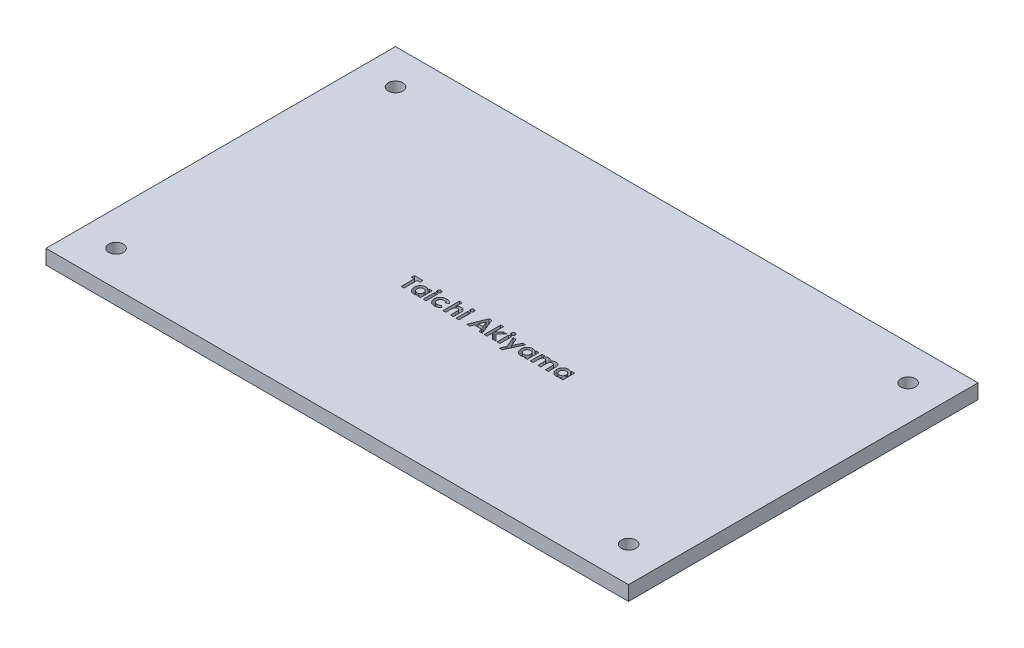
from build123d import *

# Parameters (mm, degrees)
SKETCH1_W           = 127
SKETCH1_H           = 76.2
BOSS_EXTRUDE1_DEPTH = 3.175
SKETCH2_R           = 1.5875
CUT_EXTRUDE1_DEPTH  = 3.175
SKETCH3_W           = 0.628205128
SKETCH3_H           = 2.557692308
CUT_EXTRUDE2_DEPTH  = 2.54


with BuildPart() as part:
    # Sketch1 → Boss-Extrude1 (new body)
    with BuildSketch(Plane(origin=(0, 0, 0), x_dir=(1, 0, 0), z_dir=(0, 1, 0))):
        with Locations((3.169007835, 6.5885369)):
            Rectangle(SKETCH1_W, SKETCH1_H)
    extrude(amount=BOSS_EXTRUDE1_DEPTH)

    # Sketch2 → Cut-Extrude1 (cut)
    with BuildSketch(Plane(origin=(0, 0, 0), x_dir=(1, 0, 0), z_dir=(0, 1, 0))):
        with Locations((-52.710992165, 37.0685369)):
            Circle(SKETCH2_R)
        with Locations((-52.710992165, -23.85921711)):
            Circle(SKETCH2_R)
        with Locations((59.049007835, 37.0685369)):
            Circle(SKETCH2_R)
        with Locations((59.049007835, -23.85921711)):
            Circle(SKETCH2_R)
    extrude(amount=CUT_EXTRUDE1_DEPTH, mode=Mode.SUBTRACT)

    # Sketch3 → Cut-Extrude2 (cut)
    with BuildSketch(Plane(origin=(0, 3.175, 0), x_dir=(1, 0, 0), z_dir=(0, 1, 0))):
        Polygon((-15.048272606, 3.5), (-13.163657221, 3.5), (-13.163657221, 2.871794872), (-13.79186235, 2.871794872), (-13.79186235, 0), (-14.420067478, 0), (-14.420067478, 2.871794872), (-15.048272606, 2.871794872), align=None)
        with BuildLine():
            Line((-10.830323888, 2.557692308), (-10.20211876, 2.557692308))
            Line((-10.20211876, 2.557692308), (-10.20211876, 0))
            Line((-10.20211876, 0), (-10.830323888, 0))
            Line((-10.830323888, 0), (-10.830323888, 0.279046474))
            add(Edge.make_bspline(
                [(-10.830323888, 0.279046474), (-10.861451221, 0.251884388), (-10.921863226, 0.199168144), (-11.017052999, 0.130767476), (-11.112520927, 0.074345765), (-11.208725737, 0.029408949), (-11.307146056, -0.003772264), (-11.40849047, -0.027796237), (-11.514218449, -0.041963762), (-11.586090872, -0.043892353), (-11.622591516, -0.044871795)],
                knots=[0, 0, 0, 0, 0.000123884, 0.000240435, 0.000351062, 0.000456148, 0.00055836, 0.000662098, 0.000768197, 0.000877682, 0.000877682, 0.000877682, 0.000877682], degree=3))
            add(Edge.make_bspline(
                [(-11.622591516, -0.044871795), (-11.663565112, -0.043950017), (-11.74453126, -0.042128532), (-11.863340094, -0.022954463), (-11.978061835, 0.006395724), (-12.08860336, 0.047929908), (-12.194763549, 0.101750066), (-12.297354851, 0.166451958), (-12.394618537, 0.244307005), (-12.487364294, 0.331946618), (-12.572281752, 0.428350817), (-12.646517396, 0.532181523), (-12.709092527, 0.641966128), (-12.760356984, 0.757340645), (-12.800683099, 0.878220396), (-12.829429848, 1.004988774), (-12.846390463, 1.137691055), (-12.84848971, 1.228082651), (-12.849554657, 1.273938301)],
                knots=[0, 0, 0, 0, 0.000122824, 0.000242708, 0.000360045, 0.000477637, 0.00059616, 0.000716559, 0.00084084, 0.00096929, 0.00109896, 0.001225617, 0.00135154, 0.001477401, 0.001603778, 0.001733212, 0.001866788, 0.002004323, 0.002004323, 0.002004323, 0.002004323], degree=3))
            add(Edge.make_bspline(
                [(-12.849554657, 1.273938301), (-12.848436991, 1.321421887), (-12.846244564, 1.414566232), (-12.830207091, 1.551251128), (-12.801990827, 1.681162718), (-12.763515923, 1.804480946), (-12.714024639, 1.921227119), (-12.653747563, 2.031592502), (-12.581864681, 2.13528862), (-12.499032402, 2.23055049), (-12.409593886, 2.317862595), (-12.313910485, 2.393874707), (-12.213478478, 2.458450533), (-12.108191138, 2.511169467), (-11.998063503, 2.551907991), (-11.883530352, 2.581691179), (-11.764083241, 2.599562137), (-11.6827149, 2.601555137), (-11.641521805, 2.602564103)],
                knots=[0, 0, 0, 0, 0.000142438, 0.000279408, 0.000412113, 0.000540727, 0.000666392, 0.0007919, 0.000917346, 0.001044118, 0.001170058, 0.00129182, 0.001410068, 0.00152765, 0.00164434, 0.001761677, 0.001882149, 0.002005674, 0.002005674, 0.002005674, 0.002005674], degree=3))
            add(Edge.make_bspline(
                [(-11.641521805, 2.602564103), (-11.603363651, 2.601771359), (-11.527862418, 2.600202805), (-11.416886484, 2.583171311), (-11.309255834, 2.557412387), (-11.205557598, 2.520710555), (-11.10494121, 2.474367027), (-11.009137335, 2.416295131), (-10.916050176, 2.348935605), (-10.859252373, 2.296326387), (-10.830323888, 2.26953125)],
                knots=[0, 0, 0, 0, 0.000114388, 0.000226333, 0.000336015, 0.000446, 0.000555788, 0.000667732, 0.000781602, 0.000899798, 0.000899798, 0.000899798, 0.000899798], degree=3))
            Line((-10.830323888, 2.26953125), (-10.830323888, 2.557692308))
        make_face()
        with BuildLine():
            add(Edge.make_bspline(
                [(-11.509710907, 2.019230769), (-11.53474303, 2.018462697), (-11.583804355, 2.016957326), (-11.655955749, 2.007902416), (-11.724910837, 1.99194726), (-11.790177836, 1.968376944), (-11.852729466, 1.939664864), (-11.911615869, 1.903703457), (-11.967323054, 1.861197838), (-12.019523399, 1.813177067), (-12.067111705, 1.76039346), (-12.108135602, 1.702795109), (-12.142999288, 1.641933961), (-12.172484904, 1.577627029), (-12.193589916, 1.509113362), (-12.210305076, 1.437284886), (-12.218979163, 1.3615548), (-12.220551501, 1.309947091), (-12.221349529, 1.283754006)],
                knots=[0, 0, 0, 0, 7.5102e-05, 0.000147195, 0.000217772, 0.000286959, 0.000355026, 0.000423925, 0.000493478, 0.00056493, 0.000636431, 0.00070628, 0.000776633, 0.000846612, 0.00091801, 0.00099132, 0.001067587, 0.001146191, 0.001146191, 0.001146191, 0.001146191], degree=3))
            add(Edge.make_bspline(
                [(-12.221349529, 1.283754006), (-12.220563691, 1.257323336), (-12.219015207, 1.205242005), (-12.210164825, 1.128873109), (-12.194051145, 1.055995388), (-12.170541893, 0.98719801), (-12.141831644, 0.92155267), (-12.106884814, 0.859362327), (-12.063958754, 0.801726584), (-12.016328731, 0.747281587), (-11.963057504, 0.698664318), (-11.907035106, 0.655496646), (-11.847496315, 0.619378283), (-11.785087086, 0.590187194), (-11.720017491, 0.566398909), (-11.651471754, 0.550644277), (-11.580121367, 0.540572639), (-11.531479924, 0.539170098), (-11.50690642, 0.538461538)],
                knots=[0, 0, 0, 0, 7.9304e-05, 0.000156268, 0.000230262, 0.000302763, 0.000374023, 0.000444985, 0.000516224, 0.000589238, 0.000661682, 0.000732217, 0.000801116, 0.000870115, 0.000938642, 0.001008537, 0.001080722, 0.001154423, 0.001154423, 0.001154423, 0.001154423], degree=3))
            add(Edge.make_bspline(
                [(-11.50690642, 0.538461538), (-11.481408045, 0.539233916), (-11.431417368, 0.540748197), (-11.358088861, 0.549720472), (-11.28820746, 0.565734128), (-11.222063907, 0.58943939), (-11.158647924, 0.617945374), (-11.098531783, 0.653204068), (-11.042367834, 0.695612148), (-10.989871633, 0.744067028), (-10.941768984, 0.797281645), (-10.900177759, 0.855635307), (-10.86395028, 0.917261705), (-10.835459035, 0.98361791), (-10.81283299, 1.053543), (-10.796599326, 1.127470944), (-10.787769153, 1.205481445), (-10.786234212, 1.258726651), (-10.785452093, 1.285857372)],
                knots=[0, 0, 0, 0, 7.6503e-05, 0.000149987, 0.000221246, 0.000291095, 0.000360435, 0.000429577, 0.000499689, 0.000571141, 0.000643632, 0.000714459, 0.000785771, 0.000857672, 0.000930619, 0.001005983, 0.001084339, 0.001165745, 0.001165745, 0.001165745, 0.001165745], degree=3))
            add(Edge.make_bspline(
                [(-10.785452093, 1.285857372), (-10.786224493, 1.312521457), (-10.787733215, 1.36460416), (-10.796637408, 1.440985838), (-10.812986322, 1.513462175), (-10.835146685, 1.58216639), (-10.864144799, 1.646941393), (-10.900399689, 1.707068983), (-10.941534682, 1.764632355), (-10.990169896, 1.81640935), (-11.042381713, 1.86451338), (-11.099371644, 1.905639009), (-11.159344196, 1.941082217), (-11.222667842, 1.970182458), (-11.28992893, 1.991514038), (-11.359929755, 2.0080303), (-11.433762474, 2.016951892), (-11.483981632, 2.018458747), (-11.509710907, 2.019230769)],
                knots=[0, 0, 0, 0, 8.0005e-05, 0.000156272, 0.000230267, 0.000302547, 0.000372526, 0.000442627, 0.000512887, 0.000584339, 0.000655319, 0.000725578, 0.000794719, 0.00086406, 0.000934123, 0.001006065, 0.00107955, 0.001156753, 0.001156753, 0.001156753, 0.001156753], degree=3))
        make_face(mode=Mode.SUBTRACT)
        with BuildLine():
            add(Edge.make_bspline(
                [(-9.306085106, 3.634615385), (-9.279009469, 3.633286951), (-9.225843848, 3.630678445), (-9.149676861, 3.605251308), (-9.079771004, 3.565344177), (-9.017972287, 3.510590642), (-8.966573893, 3.445204906), (-8.927303611, 3.372001228), (-8.905427773, 3.29089391), (-8.902389543, 3.234865823), (-8.900836708, 3.206229968)],
                knots=[0, 0, 0, 0, 8.0997e-05, 0.000159045, 0.000238182, 0.000321155, 0.000405032, 0.00048657, 0.000568724, 0.000654608, 0.000654608, 0.000654608, 0.000654608], degree=3))
            add(Edge.make_bspline(
                [(-8.900836708, 3.206229968), (-8.902333985, 3.177805144), (-8.905251499, 3.12241802), (-8.927807097, 3.042411771), (-8.965501206, 2.969243648), (-9.017315895, 2.904829012), (-9.078444633, 2.850957315), (-9.146822994, 2.810325694), (-9.22226008, 2.786313063), (-9.274600731, 2.7834865), (-9.301177253, 2.782051282)],
                knots=[0, 0, 0, 0, 8.5186e-05, 0.000165988, 0.000247203, 0.000330531, 0.000412514, 0.000490436, 0.000567604, 0.000647206, 0.000647206, 0.000647206, 0.000647206], degree=3))
            add(Edge.make_bspline(
                [(-9.301177253, 2.782051282), (-9.328489238, 2.783374966), (-9.382117398, 2.785974073), (-9.458909111, 2.811460703), (-9.529747334, 2.85105354), (-9.591277968, 2.906925775), (-9.643264989, 2.972776125), (-9.680819929, 3.047684049), (-9.704311473, 3.129345977), (-9.707099899, 3.186203877), (-9.708529016, 3.215344551)],
                knots=[0, 0, 0, 0, 8.1695e-05, 0.000160411, 0.000240158, 0.000323594, 0.000408023, 0.000490488, 0.000573505, 0.000660785, 0.000660785, 0.000660785, 0.000660785], degree=3))
            add(Edge.make_bspline(
                [(-9.708529016, 3.215344551), (-9.706973746, 3.243286705), (-9.703918642, 3.298175033), (-9.681911765, 3.377479097), (-9.64354195, 3.449452107), (-9.592513784, 3.513640896), (-9.531257867, 3.567373072), (-9.461393975, 3.606068197), (-9.385739595, 3.630445121), (-9.332910759, 3.633210943), (-9.306085106, 3.634615385)],
                knots=[0, 0, 0, 0, 8.3789e-05, 0.000164592, 0.000244563, 0.000326905, 0.000409417, 0.000487254, 0.000565091, 0.000645391, 0.000645391, 0.000645391, 0.000645391], degree=3))
        make_face()
        with Locations((-9.304682862, 1.278846154)):
            Rectangle(SKETCH3_W, SKETCH3_H)
        with BuildLine():
            Line((-5.939298247, 2.036057692), (-6.459530619, 1.75))
            add(Edge.make_bspline(
                [(-6.459530619, 1.75), (-6.483376175, 1.773879223), (-6.529213328, 1.819781094), (-6.602716887, 1.87788558), (-6.674907034, 1.925994478), (-6.74875987, 1.961496373), (-6.824935552, 1.988232703), (-6.906181644, 2.005940762), (-6.99344643, 2.017600889), (-7.053807582, 2.018676275), (-7.08493126, 2.019230769)],
                knots=[0, 0, 0, 0, 0.000101156, 0.000194447, 0.000280597, 0.000360872, 0.000439588, 0.000522252, 0.000609912, 0.000703227, 0.000703227, 0.000703227, 0.000703227], degree=3))
            add(Edge.make_bspline(
                [(-7.08493126, 2.019230769), (-7.11347382, 2.018541361), (-7.169329217, 2.017192247), (-7.250942815, 2.007115291), (-7.328508177, 1.991288235), (-7.401886069, 1.968133197), (-7.470945797, 1.937544132), (-7.536258455, 1.901346575), (-7.597189377, 1.858126697), (-7.652877287, 1.808498859), (-7.703145413, 1.75385971), (-7.747987147, 1.695584708), (-7.784723116, 1.63280936), (-7.81648364, 1.567009112), (-7.839834365, 1.496948089), (-7.856918323, 1.423262022), (-7.86665602, 1.345947647), (-7.86806684, 1.29312872), (-7.868785426, 1.266225962)],
                knots=[0, 0, 0, 0, 8.5609e-05, 0.000167529, 0.00024632, 0.00032282, 0.000397853, 0.000472558, 0.000546482, 0.000621476, 0.0006959, 0.000768959, 0.000841585, 0.000913719, 0.000987772, 0.001062605, 0.001140351, 0.001221056, 0.001221056, 0.001221056, 0.001221056], degree=3))
            add(Edge.make_bspline(
                [(-7.868785426, 1.266225962), (-7.868026178, 1.240025277), (-7.866543692, 1.188866583), (-7.857435797, 1.113702271), (-7.841624147, 1.042149054), (-7.817916649, 0.974585212), (-7.789500562, 0.910387902), (-7.753815158, 0.850067699), (-7.711851089, 0.793361199), (-7.663387432, 0.740761265), (-7.609701998, 0.693454078), (-7.55182489, 0.651676934), (-7.489928791, 0.616257645), (-7.423292672, 0.588461464), (-7.353002968, 0.56581339), (-7.278590283, 0.549687076), (-7.200133802, 0.540735856), (-7.146652006, 0.539231363), (-7.119286228, 0.538461538)],
                knots=[0, 0, 0, 0, 7.8604e-05, 0.00015348, 0.00022679, 0.000297963, 0.000367942, 0.000437083, 0.000507758, 0.00057921, 0.000651235, 0.000722062, 0.000793024, 0.000864649, 0.000938263, 0.001014311, 0.001092668, 0.001174774, 0.001174774, 0.001174774, 0.001174774], degree=3))
            add(Edge.make_bspline(
                [(-7.119286228, 0.538461538), (-7.085592395, 0.539232552), (-7.019826931, 0.540737458), (-6.924223031, 0.553501588), (-6.83426107, 0.574608971), (-6.749931506, 0.603823265), (-6.67135232, 0.642021499), (-6.598725413, 0.688677792), (-6.531304184, 0.743447968), (-6.491987838, 0.78614803), (-6.472150811, 0.807692308)],
                knots=[0, 0, 0, 0, 0.000101049, 0.000197233, 0.000288726, 0.000377865, 0.000464411, 0.00055018, 0.000636361, 0.000724124, 0.000724124, 0.000724124, 0.000724124], degree=3))
            Line((-6.472150811, 0.807692308), (-5.984170042, 0.47255609))
            add(Edge.make_bspline(
                [(-5.984170042, 0.47255609), (-6.017994525, 0.431201382), (-6.08474457, 0.349591011), (-6.201204889, 0.244398221), (-6.326551369, 0.154014242), (-6.463304997, 0.081870894), (-6.609474189, 0.024490084), (-6.766201117, -0.016072452), (-6.933220687, -0.039949889), (-7.04792679, -0.043204935), (-7.106666035, -0.044871795)],
                knots=[0, 0, 0, 0, 0.00016008, 0.000315906, 0.000469214, 0.000622595, 0.000778443, 0.000939317, 0.001107184, 0.001283366, 0.001283366, 0.001283366, 0.001283366], degree=3))
            add(Edge.make_bspline(
                [(-7.106666035, -0.044871795), (-7.159535, -0.043649621), (-7.262793916, -0.041262581), (-7.413291222, -0.022982361), (-7.554841753, 0.007808183), (-7.6877367, 0.05056992), (-7.811854901, 0.105962381), (-7.926793831, 0.17466973), (-8.03332875, 0.254780779), (-8.129537341, 0.346673969), (-8.215377479, 0.446700699), (-8.290316229, 0.552044748), (-8.355126688, 0.66081866), (-8.40597043, 0.774832933), (-8.447523779, 0.892310462), (-8.475587608, 1.014655523), (-8.494097431, 1.140860344), (-8.496018418, 1.226428746), (-8.496990555, 1.269731571)],
                knots=[0, 0, 0, 0, 0.000158579, 0.000309723, 0.000453985, 0.000592561, 0.000727819, 0.000860807, 0.00099346, 0.001126867, 0.001259113, 0.001388297, 0.001514315, 0.001638257, 0.001762205, 0.001887542, 0.00201426, 0.002144089, 0.002144089, 0.002144089, 0.002144089], degree=3))
            add(Edge.make_bspline(
                [(-8.496990555, 1.269731571), (-8.496469774, 1.299901016), (-8.495438268, 1.359657411), (-8.486632466, 1.448402321), (-8.472933598, 1.535641265), (-8.452345817, 1.620761873), (-8.42702648, 1.704177117), (-8.396247397, 1.78587023), (-8.358794529, 1.865419662), (-8.31701574, 1.943502108), (-8.269399556, 2.018056307), (-8.217451287, 2.089049354), (-8.161244124, 2.156046449), (-8.100117774, 2.218423199), (-8.034498449, 2.276625932), (-7.965340085, 2.331835475), (-7.890404749, 2.381204546), (-7.812297484, 2.427620591), (-7.730345476, 2.468939811), (-7.645490652, 2.504603745), (-7.558388749, 2.534905401), (-7.468830989, 2.559268544), (-7.377201772, 2.57934824), (-7.282685759, 2.592091641), (-7.186064913, 2.601048703), (-7.120709742, 2.602055924), (-7.087735747, 2.602564103)],
                knots=[0, 0, 0, 0, 9.0488e-05, 0.000179229, 0.000267292, 0.000355212, 0.000441709, 0.000528693, 0.000616837, 0.000705303, 0.000794191, 0.000881977, 0.000969055, 0.001056316, 0.001143711, 0.001232078, 0.001321528, 0.001412674, 0.001504545, 0.001596608, 0.001688626, 0.001780988, 0.00187491, 0.0019698, 0.00206692, 0.002165818, 0.002165818, 0.002165818, 0.002165818], degree=3))
            add(Edge.make_bspline(
                [(-7.087735747, 2.602564103), (-7.057107136, 2.60221782), (-6.996701039, 2.601534878), (-6.907494889, 2.594393767), (-6.820722101, 2.582264276), (-6.736235005, 2.56621747), (-6.653777014, 2.546332683), (-6.574453283, 2.519826928), (-6.497179325, 2.489743895), (-6.397649651, 2.444321656), (-6.280322381, 2.376521611), (-6.151528473, 2.279281402), (-6.036693112, 2.165524539), (-5.971935757, 2.079442685), (-5.939298247, 2.036057692)],
                knots=[0, 0, 0, 0, 9.1871e-05, 0.000181189, 0.000268247, 0.000354602, 0.000439115, 0.000522481, 0.000605287, 0.0006878, 0.00085051, 0.001010648, 0.001170782, 0.001333497, 0.001333497, 0.001333497, 0.001333497], degree=3))
        make_face()
        with BuildLine():
            Line((-5.311093119, 3.58974359), (-4.682887991, 3.58974359))
            Line((-4.682887991, 3.58974359), (-4.682887991, 2.280749199))
            add(Edge.make_bspline(
                [(-4.682887991, 2.280749199), (-4.651243967, 2.306483988), (-4.589564281, 2.356645552), (-4.492786832, 2.421994167), (-4.396209555, 2.477759015), (-4.298807624, 2.522952612), (-4.201003602, 2.558368188), (-4.102628599, 2.583484323), (-4.00358791, 2.599962724), (-3.937192512, 2.601696052), (-3.903941676, 2.602564103)],
                knots=[0, 0, 0, 0, 0.000122311, 0.000238406, 0.000349893, 0.000456546, 0.000560115, 0.000661466, 0.000760827, 0.000860508, 0.000860508, 0.000860508, 0.000860508], degree=3))
            add(Edge.make_bspline(
                [(-3.903941676, 2.602564103), (-3.872122858, 2.601719816), (-3.809659846, 2.600062412), (-3.718022821, 2.588090744), (-3.630252851, 2.56749059), (-3.546133718, 2.539172108), (-3.466244148, 2.50108792), (-3.389545263, 2.456477103), (-3.316948734, 2.403029172), (-3.272777881, 2.361828899), (-3.250496164, 2.341045673)],
                knots=[0, 0, 0, 0, 9.5445e-05, 0.000187367, 0.000276652, 0.000365562, 0.00045307, 0.000541692, 0.000631439, 0.000722795, 0.000722795, 0.000722795, 0.000722795], degree=3))
            add(Edge.make_bspline(
                [(-3.250496164, 2.341045673), (-3.232196992, 2.321625652), (-3.195333146, 2.282503844), (-3.149420209, 2.215058751), (-3.109774847, 2.141594309), (-3.077469529, 2.061420177), (-3.053443567, 1.974499035), (-3.0348426, 1.881546953), (-3.02455587, 1.781548999), (-3.023286346, 1.712629167), (-3.02263158, 1.677083333)],
                knots=[0, 0, 0, 0, 7.9943e-05, 0.000161046, 0.000243862, 0.000330051, 0.000419713, 0.000514039, 0.000614152, 0.00072078, 0.00072078, 0.00072078, 0.00072078], degree=3))
            Line((-3.02263158, 1.677083333), (-3.02263158, 0))
            Line((-3.02263158, 0), (-3.650836708, 0))
            Line((-3.650836708, 0), (-3.650836708, 1.111979167))
            add(Edge.make_bspline(
                [(-3.650836708, 1.111979167), (-3.65095877, 1.147270028), (-3.651192409, 1.214820379), (-3.653290487, 1.311824455), (-3.656716715, 1.39994895), (-3.661402237, 1.479220494), (-3.667944251, 1.5493078), (-3.674378781, 1.610713227), (-3.683407934, 1.663142434), (-3.696927947, 1.720111752), (-3.718930572, 1.781045034), (-3.750903968, 1.845997294), (-3.793611639, 1.899602871), (-3.843035207, 1.943814033), (-3.900180405, 1.977557665), (-3.963001489, 2.002480125), (-4.032572423, 2.0164959), (-4.080795863, 2.018295335), (-4.105864753, 2.019230769)],
                knots=[0, 0, 0, 0, 0.000105872, 0.000202649, 0.00029106, 0.000370439, 0.000440834, 0.000502234, 0.000555602, 0.000600326, 0.000677719, 0.000749529, 0.000816434, 0.000881995, 0.000947406, 0.001014458, 0.001083897, 0.001159078, 0.001159078, 0.001159078, 0.001159078], degree=3))
            add(Edge.make_bspline(
                [(-4.105864753, 2.019230769), (-4.138522091, 2.017954086), (-4.202485168, 2.015453559), (-4.294211051, 1.98971362), (-4.37881611, 1.94902838), (-4.455312927, 1.892640467), (-4.521971785, 1.82201236), (-4.57782162, 1.739229166), (-4.623503728, 1.645118896), (-4.643248358, 1.57649206), (-4.653440875, 1.541065705)],
                knots=[0, 0, 0, 0, 9.7761e-05, 0.000191475, 0.000283354, 0.000378151, 0.000474858, 0.000573257, 0.000676741, 0.000787163, 0.000787163, 0.000787163, 0.000787163], degree=3))
            add(Edge.make_bspline(
                [(-4.653440875, 1.541065705), (-4.655978834, 1.530115934), (-4.66176621, 1.505146874), (-4.666198292, 1.462545368), (-4.672775432, 1.411047447), (-4.675056936, 1.350344508), (-4.679330734, 1.28053018), (-4.68086776, 1.201491506), (-4.682415155, 1.11315418), (-4.682725312, 1.051216492), (-4.682887991, 1.018729968)],
                knots=[0, 0, 0, 0, 3.369e-05, 7.6825e-05, 0.000128313, 0.000189412, 0.000258911, 0.000338166, 0.000426518, 0.000523977, 0.000523977, 0.000523977, 0.000523977], degree=3))
            Line((-4.682887991, 1.018729968), (-4.682887991, 0))
            Line((-4.682887991, 0), (-5.311093119, 0))
            Line((-5.311093119, 0), (-5.311093119, 3.58974359))
        make_face()
        with BuildLine():
            add(Edge.make_bspline(
                [(-2.126597926, 3.634615385), (-2.09952229, 3.633286951), (-2.046356669, 3.630678445), (-1.970189682, 3.605251308), (-1.900283824, 3.565344177), (-1.838485107, 3.510590642), (-1.787086713, 3.445204906), (-1.747816431, 3.372001228), (-1.725940593, 3.29089391), (-1.722902363, 3.234865823), (-1.721349529, 3.206229968)],
                knots=[0, 0, 0, 0, 8.0997e-05, 0.000159045, 0.000238182, 0.000321155, 0.000405032, 0.00048657, 0.000568724, 0.000654608, 0.000654608, 0.000654608, 0.000654608], degree=3))
            add(Edge.make_bspline(
                [(-1.721349529, 3.206229968), (-1.722846805, 3.177805144), (-1.725764319, 3.12241802), (-1.748319917, 3.042411771), (-1.786014027, 2.969243648), (-1.837828715, 2.904829012), (-1.898957453, 2.850957315), (-1.967335814, 2.810325694), (-2.042772901, 2.786313063), (-2.095113552, 2.7834865), (-2.121690074, 2.782051282)],
                knots=[0, 0, 0, 0, 8.5186e-05, 0.000165988, 0.000247203, 0.000330531, 0.000412514, 0.000490436, 0.000567604, 0.000647206, 0.000647206, 0.000647206, 0.000647206], degree=3))
            add(Edge.make_bspline(
                [(-2.121690074, 2.782051282), (-2.149002058, 2.783374966), (-2.202630218, 2.785974073), (-2.279421931, 2.811460703), (-2.350260154, 2.85105354), (-2.411790789, 2.906925775), (-2.463777809, 2.972776125), (-2.50133275, 3.047684049), (-2.524824294, 3.129345977), (-2.52761272, 3.186203877), (-2.529041837, 3.215344551)],
                knots=[0, 0, 0, 0, 8.1695e-05, 0.000160411, 0.000240158, 0.000323594, 0.000408023, 0.000490488, 0.000573505, 0.000660785, 0.000660785, 0.000660785, 0.000660785], degree=3))
            add(Edge.make_bspline(
                [(-2.529041837, 3.215344551), (-2.527486567, 3.243286705), (-2.524431463, 3.298175033), (-2.502424586, 3.377479097), (-2.46405477, 3.449452107), (-2.413026604, 3.513640896), (-2.351770688, 3.567373072), (-2.281906796, 3.606068197), (-2.206252415, 3.630445121), (-2.15342358, 3.633210943), (-2.126597926, 3.634615385)],
                knots=[0, 0, 0, 0, 8.3789e-05, 0.000164592, 0.000244563, 0.000326905, 0.000409417, 0.000487254, 0.000565091, 0.000645391, 0.000645391, 0.000645391, 0.000645391], degree=3))
        make_face()
        with Locations((-2.125195683, 1.278846154)):
            Rectangle(SKETCH3_W, SKETCH3_H)
        Polygon((1.285761849, 3.5), (1.868394061, 3.5), (3.281855599, 0), (2.610882042, 0), (2.338846785, 0.717948718), (0.813906881, 0.717948718), (0.541871625, 0), (-0.128400811, 0), align=None)
        Polygon((1.576727394, 2.561197917), (1.052288292, 1.346153846), (2.101166497, 1.346153846), align=None, mode=Mode.SUBTRACT)
        Polygon((3.70813765, 3.58974359), (4.336342779, 3.58974359), (4.336342779, 1.49619391), (5.313706561, 2.557692308), (6.089848388, 2.557692308), (4.967352394, 1.338441506), (6.250405279, 0), (5.459539894, 0), (4.336342779, 1.171574519), (4.336342779, 0), (3.70813765, 0), align=None)
        with BuildLine():
            add(Edge.make_bspline(
                [(6.802889253, 3.634615385), (6.82996489, 3.633286951), (6.883130511, 3.630678445), (6.959297498, 3.605251308), (7.029203355, 3.565344177), (7.091002072, 3.510590642), (7.142400466, 3.445204906), (7.181670748, 3.372001228), (7.203546586, 3.29089391), (7.206584816, 3.234865823), (7.20813765, 3.206229968)],
                knots=[0, 0, 0, 0, 8.0997e-05, 0.000159045, 0.000238182, 0.000321155, 0.000405032, 0.00048657, 0.000568724, 0.000654608, 0.000654608, 0.000654608, 0.000654608], degree=3))
            add(Edge.make_bspline(
                [(7.20813765, 3.206229968), (7.206640374, 3.177805144), (7.20372286, 3.12241802), (7.181167262, 3.042411771), (7.143473153, 2.969243648), (7.091658464, 2.904829012), (7.030529726, 2.850957315), (6.962151365, 2.810325694), (6.886714279, 2.786313063), (6.834373627, 2.7834865), (6.807797106, 2.782051282)],
                knots=[0, 0, 0, 0, 8.5186e-05, 0.000165988, 0.000247203, 0.000330531, 0.000412514, 0.000490436, 0.000567604, 0.000647206, 0.000647206, 0.000647206, 0.000647206], degree=3))
            add(Edge.make_bspline(
                [(6.807797106, 2.782051282), (6.780485121, 2.783374966), (6.726856961, 2.785974073), (6.650065248, 2.811460703), (6.579227025, 2.85105354), (6.517696391, 2.906925775), (6.46570937, 2.972776125), (6.42815443, 3.047684049), (6.404662886, 3.129345977), (6.40187446, 3.186203877), (6.400445343, 3.215344551)],
                knots=[0, 0, 0, 0, 8.1695e-05, 0.000160411, 0.000240158, 0.000323594, 0.000408023, 0.000490488, 0.000573505, 0.000660785, 0.000660785, 0.000660785, 0.000660785], degree=3))
            add(Edge.make_bspline(
                [(6.400445343, 3.215344551), (6.402000613, 3.243286705), (6.405055717, 3.298175033), (6.427062594, 3.377479097), (6.465432409, 3.449452107), (6.516460575, 3.513640896), (6.577716491, 3.567373072), (6.647580384, 3.606068197), (6.723234764, 3.630445121), (6.7760636, 3.633210943), (6.802889253, 3.634615385)],
                knots=[0, 0, 0, 0, 8.3789e-05, 0.000164592, 0.000244563, 0.000326905, 0.000409417, 0.000487254, 0.000565091, 0.000645391, 0.000645391, 0.000645391, 0.000645391], degree=3))
        make_face()
        with Locations((6.804291497, 1.278846154)):
            Rectangle(SKETCH3_W, SKETCH3_H)
        Polygon((7.453530279, 2.557692308), (8.082436529, 2.557692308), (8.780753836, 0.912159455), (9.553390054, 2.557692308), (10.192112009, 2.557692308), (8.5479814, -0.942307692), (7.909259445, -0.942307692), (8.449824349, 0.208233173), align=None)
        with BuildLine():
            Line((12.45813765, 2.557692308), (13.086342779, 2.557692308))
            Line((13.086342779, 2.557692308), (13.086342779, 0))
            Line((13.086342779, 0), (12.45813765, 0))
            Line((12.45813765, 0), (12.45813765, 0.279046474))
            add(Edge.make_bspline(
                [(12.45813765, 0.279046474), (12.427010318, 0.251884388), (12.366598312, 0.199168144), (12.271408539, 0.130767476), (12.175940611, 0.074345765), (12.079735802, 0.029408949), (11.981315483, -0.003772264), (11.879971068, -0.027796237), (11.77424309, -0.041963762), (11.702370667, -0.043892353), (11.665870022, -0.044871795)],
                knots=[0, 0, 0, 0, 0.000123884, 0.000240435, 0.000351062, 0.000456148, 0.00055836, 0.000662098, 0.000768197, 0.000877682, 0.000877682, 0.000877682, 0.000877682], degree=3))
            add(Edge.make_bspline(
                [(11.665870022, -0.044871795), (11.624896426, -0.043950017), (11.543930278, -0.042128532), (11.425121444, -0.022954463), (11.310399704, 0.006395724), (11.199858179, 0.047929908), (11.093697989, 0.101750066), (10.991106688, 0.166451958), (10.893843002, 0.244307005), (10.801097245, 0.331946618), (10.716179786, 0.428350817), (10.641944142, 0.532181523), (10.579369011, 0.641966128), (10.528104555, 0.757340645), (10.48777844, 0.878220396), (10.45903169, 1.004988774), (10.442071075, 1.137691055), (10.439971829, 1.228082651), (10.438906881, 1.273938301)],
                knots=[0, 0, 0, 0, 0.000122824, 0.000242708, 0.000360045, 0.000477637, 0.00059616, 0.000716559, 0.00084084, 0.00096929, 0.00109896, 0.001225617, 0.00135154, 0.001477401, 0.001603778, 0.001733212, 0.001866788, 0.002004323, 0.002004323, 0.002004323, 0.002004323], degree=3))
            add(Edge.make_bspline(
                [(10.438906881, 1.273938301), (10.440024548, 1.321421887), (10.442216975, 1.414566232), (10.458254448, 1.551251128), (10.486470712, 1.681162718), (10.524945616, 1.804480946), (10.574436899, 1.921227119), (10.634713975, 2.031592502), (10.706596857, 2.13528862), (10.789429136, 2.23055049), (10.878867653, 2.317862595), (10.974551054, 2.393874707), (11.074983061, 2.458450533), (11.1802704, 2.511169467), (11.290398036, 2.551907991), (11.404931186, 2.581691179), (11.524378298, 2.599562137), (11.605746638, 2.601555137), (11.646939734, 2.602564103)],
                knots=[0, 0, 0, 0, 0.000142438, 0.000279408, 0.000412113, 0.000540727, 0.000666392, 0.0007919, 0.000917346, 0.001044118, 0.001170058, 0.00129182, 0.001410068, 0.00152765, 0.00164434, 0.001761677, 0.001882149, 0.002005674, 0.002005674, 0.002005674, 0.002005674], degree=3))
            add(Edge.make_bspline(
                [(11.646939734, 2.602564103), (11.685097888, 2.601771359), (11.760599121, 2.600202805), (11.871575055, 2.583171311), (11.979205705, 2.557412387), (12.08290394, 2.520710555), (12.183520328, 2.474367027), (12.279324204, 2.416295131), (12.372411363, 2.348935605), (12.429209166, 2.296326387), (12.45813765, 2.26953125)],
                knots=[0, 0, 0, 0, 0.000114388, 0.000226333, 0.000336015, 0.000446, 0.000555788, 0.000667732, 0.000781602, 0.000899798, 0.000899798, 0.000899798, 0.000899798], degree=3))
            Line((12.45813765, 2.26953125), (12.45813765, 2.557692308))
        make_face()
        with BuildLine():
            add(Edge.make_bspline(
                [(11.778750631, 2.019230769), (11.753718509, 2.018462697), (11.704657183, 2.016957326), (11.63250579, 2.007902416), (11.563550702, 1.99194726), (11.498283702, 1.968376944), (11.435732073, 1.939664864), (11.376845669, 1.903703457), (11.321138485, 1.861197838), (11.268938139, 1.813177067), (11.221349833, 1.76039346), (11.180325936, 1.702795109), (11.145462251, 1.641933961), (11.115976634, 1.577627029), (11.094871623, 1.509113362), (11.078156462, 1.437284886), (11.069482376, 1.3615548), (11.067910037, 1.309947091), (11.067112009, 1.283754006)],
                knots=[0, 0, 0, 0, 7.5102e-05, 0.000147195, 0.000217772, 0.000286959, 0.000355026, 0.000423925, 0.000493478, 0.00056493, 0.000636431, 0.00070628, 0.000776633, 0.000846612, 0.00091801, 0.00099132, 0.001067587, 0.001146191, 0.001146191, 0.001146191, 0.001146191], degree=3))
            add(Edge.make_bspline(
                [(11.067112009, 1.283754006), (11.067897847, 1.257323336), (11.069446332, 1.205242005), (11.078296713, 1.128873109), (11.094410394, 1.055995388), (11.117919645, 0.98719801), (11.146629895, 0.92155267), (11.181576725, 0.859362327), (11.224502785, 0.801726584), (11.272132807, 0.747281587), (11.325404035, 0.698664318), (11.381426433, 0.655496646), (11.440965223, 0.619378283), (11.503374452, 0.590187194), (11.568444047, 0.566398909), (11.636989784, 0.550644277), (11.708340171, 0.540572639), (11.756981614, 0.539170098), (11.781555118, 0.538461538)],
                knots=[0, 0, 0, 0, 7.9304e-05, 0.000156268, 0.000230262, 0.000302763, 0.000374023, 0.000444985, 0.000516224, 0.000589238, 0.000661682, 0.000732217, 0.000801116, 0.000870115, 0.000938642, 0.001008537, 0.001080722, 0.001154423, 0.001154423, 0.001154423, 0.001154423], degree=3))
            add(Edge.make_bspline(
                [(11.781555118, 0.538461538), (11.807053494, 0.539233916), (11.85704417, 0.540748197), (11.930372677, 0.549720472), (12.000254079, 0.565734128), (12.066397631, 0.58943939), (12.129813614, 0.617945374), (12.189929756, 0.653204068), (12.246093705, 0.695612148), (12.298589906, 0.744067028), (12.346692554, 0.797281645), (12.388283779, 0.855635307), (12.424511258, 0.917261705), (12.453002504, 0.98361791), (12.475628548, 1.053543), (12.491862213, 1.127470944), (12.500692385, 1.205481445), (12.502227327, 1.258726651), (12.503009445, 1.285857372)],
                knots=[0, 0, 0, 0, 7.6503e-05, 0.000149987, 0.000221246, 0.000291095, 0.000360435, 0.000429577, 0.000499689, 0.000571141, 0.000643632, 0.000714459, 0.000785771, 0.000857672, 0.000930619, 0.001005983, 0.001084339, 0.001165745, 0.001165745, 0.001165745, 0.001165745], degree=3))
            add(Edge.make_bspline(
                [(12.503009445, 1.285857372), (12.502237045, 1.312521457), (12.500728324, 1.36460416), (12.491824131, 1.440985838), (12.475475216, 1.513462175), (12.453314853, 1.58216639), (12.42431674, 1.646941393), (12.38806185, 1.707068983), (12.346926856, 1.764632355), (12.298291642, 1.81640935), (12.246079825, 1.86451338), (12.189089894, 1.905639009), (12.129117342, 1.941082217), (12.065793696, 1.970182458), (11.998532608, 1.991514038), (11.928531784, 2.0080303), (11.854699065, 2.016951892), (11.804479906, 2.018458747), (11.778750631, 2.019230769)],
                knots=[0, 0, 0, 0, 8.0005e-05, 0.000156272, 0.000230267, 0.000302547, 0.000372526, 0.000442627, 0.000512887, 0.000584339, 0.000655319, 0.000725578, 0.000794719, 0.00086406, 0.000934123, 0.001006065, 0.00107955, 0.001156753, 0.001156753, 0.001156753, 0.001156753], degree=3))
        make_face(mode=Mode.SUBTRACT)
        with BuildLine():
            Line((13.714547907, 2.557692308), (14.342753035, 2.557692308))
            Line((14.342753035, 2.557692308), (14.342753035, 2.252003205))
            add(Edge.make_bspline(
                [(14.342753035, 2.252003205), (14.37069528, 2.28020496), (14.425711264, 2.335731898), (14.516883511, 2.407116768), (14.611985396, 2.468159651), (14.712169405, 2.517577707), (14.81719049, 2.555311961), (14.926550906, 2.582963067), (15.040812374, 2.599276353), (15.118608991, 2.601456038), (15.158157683, 2.602564103)],
                knots=[0, 0, 0, 0, 0.000119001, 0.000234303, 0.000346528, 0.000457527, 0.000568643, 0.000680705, 0.000795425, 0.000914048, 0.000914048, 0.000914048, 0.000914048], degree=3))
            add(Edge.make_bspline(
                [(15.158157683, 2.602564103), (15.197758592, 2.601318478), (15.275711701, 2.598866505), (15.389444745, 2.57642866), (15.497188632, 2.539974743), (15.597757928, 2.488014163), (15.691879487, 2.423845548), (15.775383663, 2.344153745), (15.850547456, 2.252111111), (15.890612651, 2.182525891), (15.91116249, 2.146834936)],
                knots=[0, 0, 0, 0, 0.000118697, 0.000233651, 0.000346285, 0.000458854, 0.000572239, 0.000686814, 0.000803976, 0.00092735, 0.00092735, 0.00092735, 0.00092735], degree=3))
            add(Edge.make_bspline(
                [(15.91116249, 2.146834936), (15.937633338, 2.182622984), (15.989588185, 2.252864879), (16.081682882, 2.344573637), (16.181264727, 2.423853858), (16.290260398, 2.488487901), (16.405775349, 2.539797384), (16.5273041, 2.576293213), (16.653744831, 2.598829005), (16.739794687, 2.601308727), (16.783358003, 2.602564103)],
                knots=[0, 0, 0, 0, 0.000133377, 0.000261782, 0.000388582, 0.000514355, 0.000640857, 0.00076684, 0.000894209, 0.001024806, 0.001024806, 0.001024806, 0.001024806], degree=3))
            add(Edge.make_bspline(
                [(16.783358003, 2.602564103), (16.828353736, 2.601260589), (16.915978742, 2.598722116), (17.04295996, 2.573747991), (17.161893236, 2.535159221), (17.270150179, 2.479003117), (17.368039548, 2.412483987), (17.451453098, 2.333888859), (17.520678724, 2.245960253), (17.565753484, 2.163856389), (17.594893105, 2.091267172), (17.612487867, 2.028100951), (17.628944413, 1.957567877), (17.640766794, 1.878719886), (17.651802466, 1.792298087), (17.658209108, 1.697727919), (17.662563768, 1.595327968), (17.663026288, 1.524477999), (17.663265856, 1.487780449)],
                knots=[0, 0, 0, 0, 0.000134836, 0.000262581, 0.000386741, 0.000508716, 0.000627156, 0.000740739, 0.000851119, 0.000961576, 0.001020424, 0.001085432, 0.001158059, 0.001237592, 0.001324469, 0.00141938, 0.00152183, 0.001631915, 0.001631915, 0.001631915, 0.001631915], degree=3))
            Line((17.663265856, 1.487780449), (17.663265856, 0))
            Line((17.663265856, 0), (17.035060727, 0))
            Line((17.035060727, 0), (17.035060727, 1.284455128))
            add(Edge.make_bspline(
                [(17.035060727, 1.284455128), (17.034537866, 1.318811915), (17.03353428, 1.384756664), (17.029267649, 1.479341815), (17.019717105, 1.565122385), (17.008522643, 1.642573517), (16.992503153, 1.711284558), (16.972970293, 1.771421143), (16.950312294, 1.823069838), (16.922953444, 1.866225258), (16.892311499, 1.902568939), (16.858226756, 1.93372267), (16.8210546, 1.960302968), (16.78045801, 1.982958895), (16.735373462, 1.998281547), (16.687322936, 2.010304246), (16.635930425, 2.01849179), (16.600397654, 2.018979908), (16.582136048, 2.019230769)],
                knots=[0, 0, 0, 0, 0.000103086, 0.000197865, 0.000283886, 0.000361925, 0.000432502, 0.000495247, 0.000551416, 0.00060121, 0.000647981, 0.000693635, 0.000739359, 0.00078485, 0.000832532, 0.000881676, 0.000933435, 0.000988163, 0.000988163, 0.000988163, 0.000988163], degree=3))
            add(Edge.make_bspline(
                [(16.582136048, 2.019230769), (16.553995172, 2.018257866), (16.498774302, 2.016348738), (16.41830624, 1.998104876), (16.342585201, 1.968278115), (16.271894866, 1.927701449), (16.207756336, 1.877021959), (16.151651358, 1.816911252), (16.10531647, 1.747022904), (16.073242332, 1.682180536), (16.053200024, 1.623550006), (16.039061998, 1.573337666), (16.028041968, 1.516554936), (16.019416511, 1.453776894), (16.011141393, 1.384648651), (16.007081666, 1.30925762), (16.002927326, 1.227708538), (16.002981407, 1.171347631), (16.003009445, 1.142127404)],
                knots=[0, 0, 0, 0, 8.4321e-05, 0.000165464, 0.000246056, 0.000327715, 0.000409073, 0.000490433, 0.000573272, 0.000659817, 0.000706604, 0.000758996, 0.000816196, 0.000879952, 0.000949094, 0.001024974, 0.001106379, 0.001194022, 0.001194022, 0.001194022, 0.001194022], degree=3))
            Line((16.003009445, 1.142127404), (16.003009445, 0))
            Line((16.003009445, 0), (15.374804317, 0))
            Line((15.374804317, 0), (15.374804317, 1.226262019))
            add(Edge.make_bspline(
                [(15.374804317, 1.226262019), (15.374751573, 1.253609277), (15.37465011, 1.306216542), (15.371600337, 1.38218244), (15.367561842, 1.452326529), (15.361900343, 1.516844453), (15.355370918, 1.575655969), (15.345947453, 1.628439335), (15.336047234, 1.675485406), (15.319073174, 1.728928337), (15.295154542, 1.78815205), (15.259419755, 1.850955499), (15.216211517, 1.903538586), (15.166621913, 1.946310521), (15.110583534, 1.978899303), (15.049516004, 2.003141307), (14.982253279, 2.016226397), (14.935954116, 2.018208178), (14.912063933, 2.019230769)],
                knots=[0, 0, 0, 0, 8.2034e-05, 0.000157807, 0.000228046, 0.000292792, 0.000352102, 0.000405471, 0.000453609, 0.000496187, 0.000573527, 0.000644838, 0.000712076, 0.000776717, 0.000840206, 0.000905696, 0.000972934, 0.001044617, 0.001044617, 0.001044617, 0.001044617], degree=3))
            add(Edge.make_bspline(
                [(14.912063933, 2.019230769), (14.885070081, 2.018314551), (14.831608534, 2.016499974), (14.753733622, 1.997009927), (14.679277985, 1.967730431), (14.60987957, 1.92602202), (14.54670729, 1.874149887), (14.491164042, 1.812329381), (14.445072662, 1.740633832), (14.412856152, 1.674002879), (14.393106086, 1.613909599), (14.378587908, 1.562393448), (14.367977893, 1.504360235), (14.359125475, 1.440461569), (14.350899348, 1.370622026), (14.346822824, 1.294534478), (14.342672589, 1.212283263), (14.342725573, 1.155455403), (14.342753035, 1.126001603)],
                knots=[0, 0, 0, 0, 8.0824e-05, 0.000160072, 0.000239361, 0.000320164, 0.000401856, 0.000483779, 0.000568371, 0.000656812, 0.000704925, 0.000757993, 0.000817257, 0.000881707, 0.000951546, 0.001028125, 0.001110231, 0.001198575, 0.001198575, 0.001198575, 0.001198575], degree=3))
            Line((14.342753035, 1.126001603), (14.342753035, 0))
            Line((14.342753035, 0), (13.714547907, 0))
            Line((13.714547907, 0), (13.714547907, 2.557692308))
        make_face()
        with BuildLine():
            Line((20.220958163, 2.557692308), (20.849163292, 2.557692308))
            Line((20.849163292, 2.557692308), (20.849163292, 0))
            Line((20.849163292, 0), (20.220958163, 0))
            Line((20.220958163, 0), (20.220958163, 0.279046474))
            add(Edge.make_bspline(
                [(20.220958163, 0.279046474), (20.189830831, 0.251884388), (20.129418825, 0.199168144), (20.034229052, 0.130767476), (19.938761124, 0.074345765), (19.842556314, 0.029408949), (19.744135996, -0.003772264), (19.642791581, -0.027796237), (19.537063603, -0.041963762), (19.46519118, -0.043892353), (19.428690535, -0.044871795)],
                knots=[0, 0, 0, 0, 0.000123884, 0.000240435, 0.000351062, 0.000456148, 0.00055836, 0.000662098, 0.000768197, 0.000877682, 0.000877682, 0.000877682, 0.000877682], degree=3))
            add(Edge.make_bspline(
                [(19.428690535, -0.044871795), (19.387716939, -0.043950017), (19.306750791, -0.042128532), (19.187941957, -0.022954463), (19.073220217, 0.006395724), (18.962678691, 0.047929908), (18.856518502, 0.101750066), (18.7539272, 0.166451958), (18.656663515, 0.244307005), (18.563917758, 0.331946618), (18.479000299, 0.428350817), (18.404764655, 0.532181523), (18.342189524, 0.641966128), (18.290925068, 0.757340645), (18.250598953, 0.878220396), (18.221852203, 1.004988774), (18.204891588, 1.137691055), (18.202792342, 1.228082651), (18.201727394, 1.273938301)],
                knots=[0, 0, 0, 0, 0.000122824, 0.000242708, 0.000360045, 0.000477637, 0.00059616, 0.000716559, 0.00084084, 0.00096929, 0.00109896, 0.001225617, 0.00135154, 0.001477401, 0.001603778, 0.001733212, 0.001866788, 0.002004323, 0.002004323, 0.002004323, 0.002004323], degree=3))
            add(Edge.make_bspline(
                [(18.201727394, 1.273938301), (18.20284506, 1.321421887), (18.205037488, 1.414566232), (18.221074961, 1.551251128), (18.249291225, 1.681162718), (18.287766129, 1.804480946), (18.337257412, 1.921227119), (18.397534488, 2.031592502), (18.46941737, 2.13528862), (18.552249649, 2.23055049), (18.641688165, 2.317862595), (18.737371567, 2.393874707), (18.837803574, 2.458450533), (18.943090913, 2.511169467), (19.053218549, 2.551907991), (19.167751699, 2.581691179), (19.287198811, 2.599562137), (19.368567151, 2.601555137), (19.409760247, 2.602564103)],
                knots=[0, 0, 0, 0, 0.000142438, 0.000279408, 0.000412113, 0.000540727, 0.000666392, 0.0007919, 0.000917346, 0.001044118, 0.001170058, 0.00129182, 0.001410068, 0.00152765, 0.00164434, 0.001761677, 0.001882149, 0.002005674, 0.002005674, 0.002005674, 0.002005674], degree=3))
            add(Edge.make_bspline(
                [(19.409760247, 2.602564103), (19.447918401, 2.601771359), (19.523419634, 2.600202805), (19.634395568, 2.583171311), (19.742026217, 2.557412387), (19.845724453, 2.520710555), (19.946340841, 2.474367027), (20.042144716, 2.416295131), (20.135231875, 2.348935605), (20.192029679, 2.296326387), (20.220958163, 2.26953125)],
                knots=[0, 0, 0, 0, 0.000114388, 0.000226333, 0.000336015, 0.000446, 0.000555788, 0.000667732, 0.000781602, 0.000899798, 0.000899798, 0.000899798, 0.000899798], degree=3))
            Line((20.220958163, 2.26953125), (20.220958163, 2.557692308))
        make_face()
        with BuildLine():
            add(Edge.make_bspline(
                [(19.541571144, 2.019230769), (19.516539022, 2.018462697), (19.467477696, 2.016957326), (19.395326302, 2.007902416), (19.326371215, 1.99194726), (19.261104215, 1.968376944), (19.198552585, 1.939664864), (19.139666182, 1.903703457), (19.083958998, 1.861197838), (19.031758652, 1.813177067), (18.984170346, 1.76039346), (18.943146449, 1.702795109), (18.908282764, 1.641933961), (18.878797147, 1.577627029), (18.857692135, 1.509113362), (18.840976975, 1.437284886), (18.832302889, 1.3615548), (18.83073055, 1.309947091), (18.829932522, 1.283754006)],
                knots=[0, 0, 0, 0, 7.5102e-05, 0.000147195, 0.000217772, 0.000286959, 0.000355026, 0.000423925, 0.000493478, 0.00056493, 0.000636431, 0.00070628, 0.000776633, 0.000846612, 0.00091801, 0.00099132, 0.001067587, 0.001146191, 0.001146191, 0.001146191, 0.001146191], degree=3))
            add(Edge.make_bspline(
                [(18.829932522, 1.283754006), (18.83071836, 1.257323336), (18.832266844, 1.205242005), (18.841117226, 1.128873109), (18.857230906, 1.055995388), (18.880740158, 0.98719801), (18.909450408, 0.92155267), (18.944397238, 0.859362327), (18.987323298, 0.801726584), (19.03495332, 0.747281587), (19.088224547, 0.698664318), (19.144246946, 0.655496646), (19.203785736, 0.619378283), (19.266194965, 0.590187194), (19.33126456, 0.566398909), (19.399810297, 0.550644277), (19.471160684, 0.540572639), (19.519802127, 0.539170098), (19.544375631, 0.538461538)],
                knots=[0, 0, 0, 0, 7.9304e-05, 0.000156268, 0.000230262, 0.000302763, 0.000374023, 0.000444985, 0.000516224, 0.000589238, 0.000661682, 0.000732217, 0.000801116, 0.000870115, 0.000938642, 0.001008537, 0.001080722, 0.001154423, 0.001154423, 0.001154423, 0.001154423], degree=3))
            add(Edge.make_bspline(
                [(19.544375631, 0.538461538), (19.569874006, 0.539233916), (19.619864683, 0.540748197), (19.69319319, 0.549720472), (19.763074592, 0.565734128), (19.829218144, 0.58943939), (19.892634127, 0.617945374), (19.952750269, 0.653204068), (20.008914217, 0.695612148), (20.061410418, 0.744067028), (20.109513067, 0.797281645), (20.151104292, 0.855635307), (20.187331771, 0.917261705), (20.215823016, 0.98361791), (20.238449061, 1.053543), (20.254682726, 1.127470944), (20.263512898, 1.205481445), (20.26504784, 1.258726651), (20.265829958, 1.285857372)],
                knots=[0, 0, 0, 0, 7.6503e-05, 0.000149987, 0.000221246, 0.000291095, 0.000360435, 0.000429577, 0.000499689, 0.000571141, 0.000643632, 0.000714459, 0.000785771, 0.000857672, 0.000930619, 0.001005983, 0.001084339, 0.001165745, 0.001165745, 0.001165745, 0.001165745], degree=3))
            add(Edge.make_bspline(
                [(20.265829958, 1.285857372), (20.265057558, 1.312521457), (20.263548837, 1.36460416), (20.254644644, 1.440985838), (20.238295729, 1.513462175), (20.216135366, 1.58216639), (20.187137252, 1.646941393), (20.150882363, 1.707068983), (20.109747369, 1.764632355), (20.061112155, 1.81640935), (20.008900338, 1.86451338), (19.951910407, 1.905639009), (19.891937855, 1.941082217), (19.828614209, 1.970182458), (19.761353121, 1.991514038), (19.691352296, 2.0080303), (19.617519578, 2.016951892), (19.567300419, 2.018458747), (19.541571144, 2.019230769)],
                knots=[0, 0, 0, 0, 8.0005e-05, 0.000156272, 0.000230267, 0.000302547, 0.000372526, 0.000442627, 0.000512887, 0.000584339, 0.000655319, 0.000725578, 0.000794719, 0.00086406, 0.000934123, 0.001006065, 0.00107955, 0.001156753, 0.001156753, 0.001156753, 0.001156753], degree=3))
        make_face(mode=Mode.SUBTRACT)
    extrude(amount=-CUT_EXTRUDE2_DEPTH, mode=Mode.SUBTRACT)


solid = part.part
